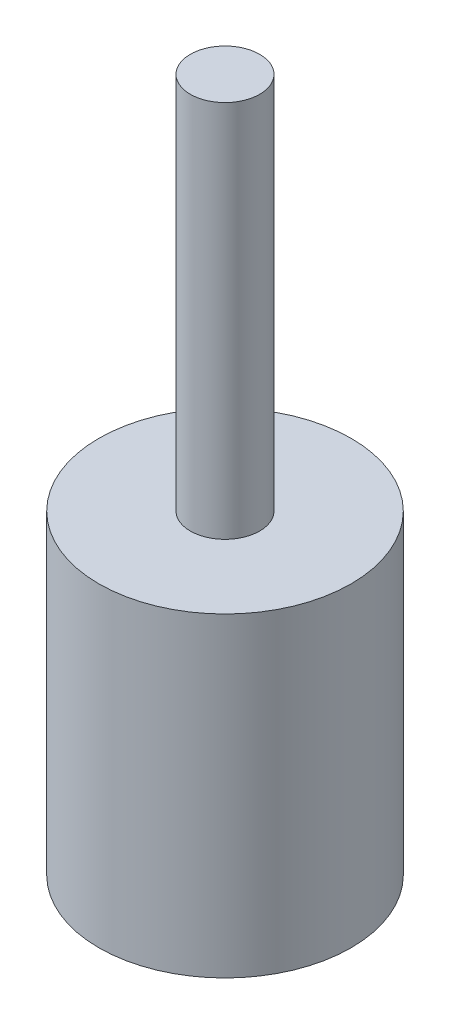
from build123d import *

# Parameters (mm, degrees)
ESBO_O1_W = 40
ESBO_O1_H = 100
ESBO_O2_W = 11
ESBO_O2_H = 120


with BuildPart() as part:
    # Esboço1 → Revolução1 (revolve)
    with BuildSketch(Plane.XY):
        with Locations((20, 50)):
            Rectangle(ESBO_O1_W, ESBO_O1_H)
    revolve(axis=Axis((0, 0, 0), (0, 1, 0)))

    # Esboço2 → Revolução2 (revolve)
    with BuildSketch(Plane.XY):
        with Locations((5.5, 160)):
            Rectangle(ESBO_O2_W, ESBO_O2_H)
    revolve(axis=Axis((0, 100, 0), (0, 1, 0)))


solid = part.part
